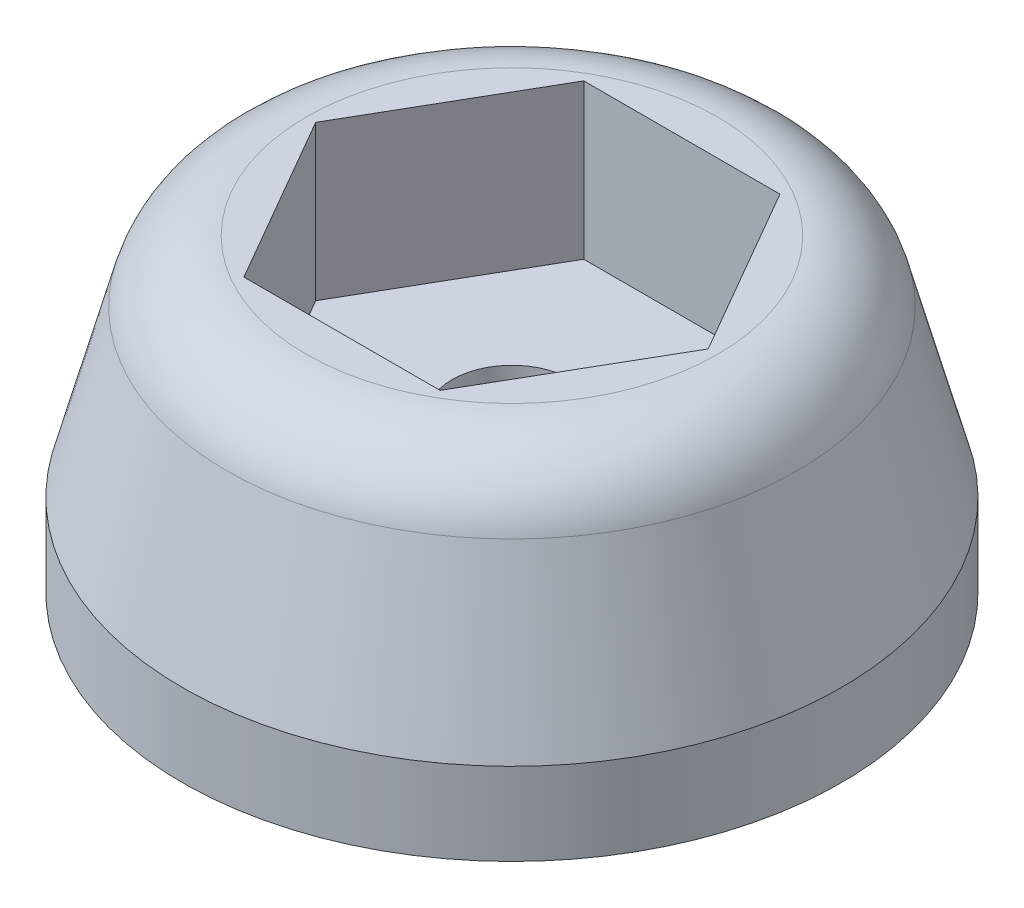
from build123d import *

# Parameters (mm, degrees)
CUT_EXTRUDE1_DEPTH = 3.81


with BuildPart() as part:
    # Sketch1 → Revolve1 (revolve)
    with BuildSketch(Plane.XY):
        with BuildLine():
            Line((-1.4732, 0), (-8.128, 0))
            Line((-8.128, 0), (-8.128, 2.032))
            Line((-8.128, 2.032), (-7.034252752, 6.1139203))
            ThreePointArc((-7.034252752, 6.1139203), (-6.308494697, 7.200093987), (-5.071491473, 7.62))
            Line((-5.071491473, 7.62), (-1.4732, 7.62))
            Line((-1.4732, 7.62), (-1.4732, 0))
        make_face()
    revolve(axis=Axis((0, 0, 0), (0, -1, 0)))

    # Sketch2 → Cut-Extrude1 (cut)
    with BuildSketch(Plane(origin=(0, 7.62, 0), x_dir=(1, 0, 0), z_dir=(0, 1, 0))):
        Polygon((-4.839349956, 0), (-2.419674978, -4.191), (2.419674978, -4.191), (4.839349956, 0), (2.419674978, 4.191), (-2.419674978, 4.191), align=None)
    extrude(amount=-CUT_EXTRUDE1_DEPTH, mode=Mode.SUBTRACT)


solid = part.part
